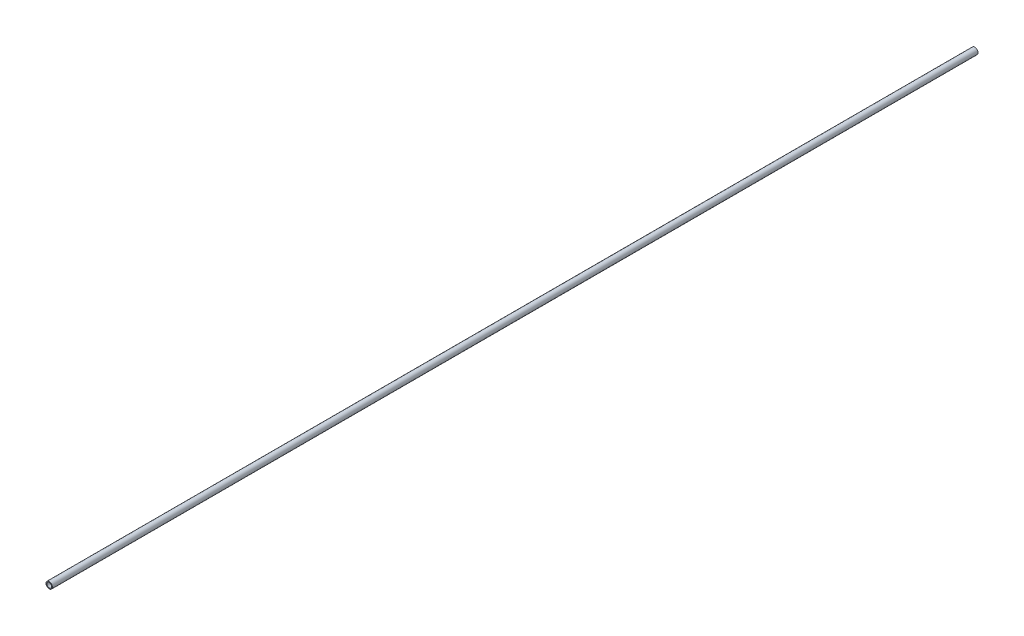
from build123d import *

# Parameters (mm, degrees)
SKETCH1_R           = 6.35
SKETCH1_R_2         = 4.699
BOSS_EXTRUDE1_DEPTH = 1828.8


with BuildPart() as part:
    # Sketch1 → Boss-Extrude1 (new body)
    with BuildSketch(Plane.XY):
        Circle(SKETCH1_R)
        Circle(SKETCH1_R_2, mode=Mode.SUBTRACT)
    extrude(amount=BOSS_EXTRUDE1_DEPTH)


solid = part.part
